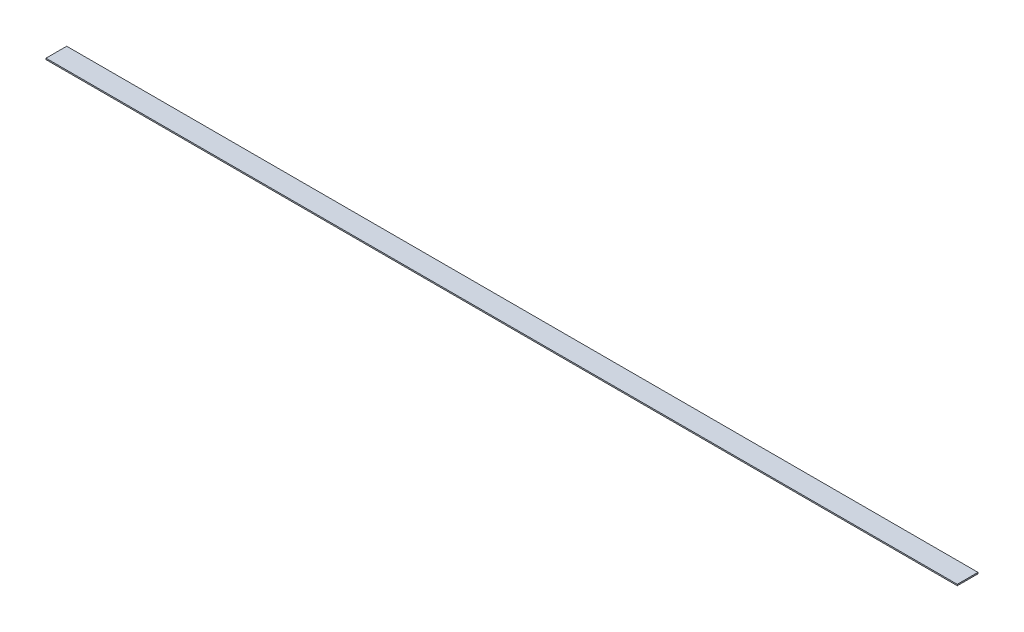
from build123d import *

# Parameters (mm, degrees)
SKETCH1_W           = 2235.2
SKETCH1_H           = 50.8
BOSS_EXTRUDE1_DEPTH = 3.175


with BuildPart() as part:
    # Sketch1 → Boss-Extrude1 (new body)
    with BuildSketch(Plane(origin=(0, 0, 0), x_dir=(1, 0, 0), z_dir=(0, 1, 0))):
        Rectangle(SKETCH1_W, SKETCH1_H)
    extrude(amount=BOSS_EXTRUDE1_DEPTH)


solid = part.part
